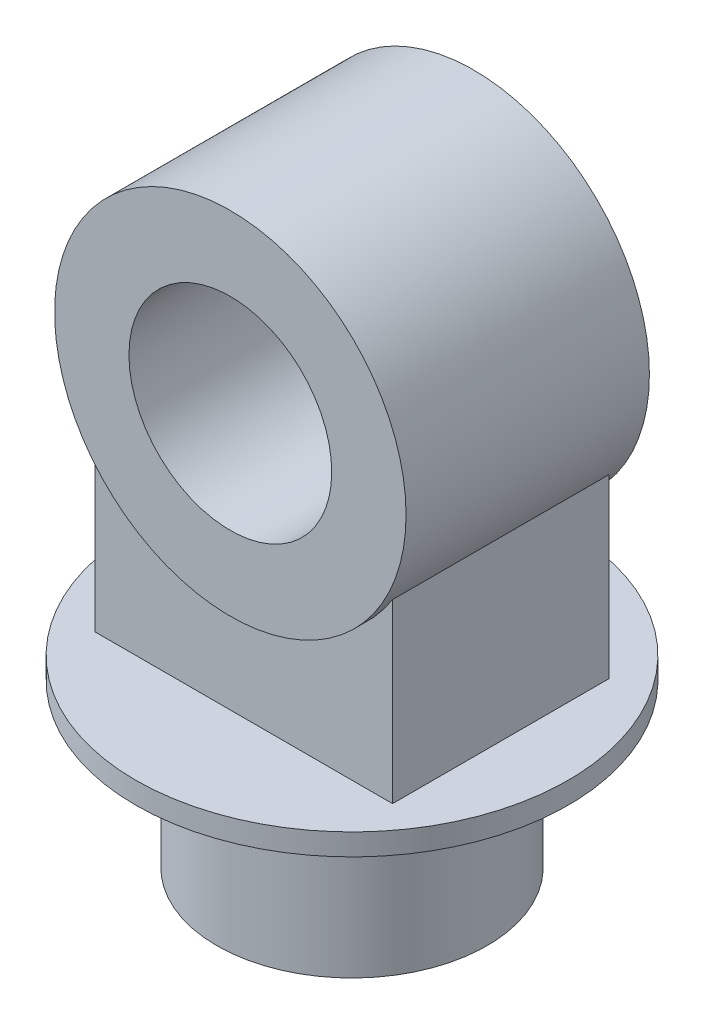
from build123d import *

# Parameters (mm, degrees)
SKETCH1_R                = 100
BOSS_EXTRUDE1_DEPTH      = 120
SKETCH2_R                = 160
BOSS_EXTRUDE2_DEPTH      = 16
SKETCH3_R                = 130
SKETCH3_R_2              = 75
BOSS_EXTRUDE3_DEPTH      = 90
BOSS_EXTRUDE4_REACH      = 402.125
BOSS_EXTRUDE4_END_RADIUS = 130
SKETCH4_W                = 220
SKETCH4_H                = 160


with BuildPart() as part:
    # Sketch1 → Boss-Extrude1 (new body)
    with BuildSketch(Plane(origin=(0, 0, 0), x_dir=(1, 0, 0), z_dir=(0, 1, 0))):
        with Locations(Location((0, 0, 0), (0, 0, 270))):
            Circle(SKETCH1_R)
    extrude(amount=BOSS_EXTRUDE1_DEPTH)

    # Sketch2 → Boss-Extrude2 (add)
    with BuildSketch(Plane(origin=(0, 120, 0), x_dir=(1, 0, 0), z_dir=(0, 1, 0))):
        with Locations(Location((0, 0, 0), (0, 0, 270))):
            Circle(SKETCH2_R)
    extrude(amount=BOSS_EXTRUDE2_DEPTH)



with BuildPart() as body_2:
    # Sketch3 → Boss-Extrude3 (new, symmetric)
    with BuildSketch(Plane.XY):
        with Locations(Location((0, 336, 0), (0, 0, 180))):
            Circle(SKETCH3_R)
        with Locations(Location((0, 336, 0), (0, 0, 180))):
            Circle(SKETCH3_R_2, mode=Mode.SUBTRACT)
    extrude(amount=BOSS_EXTRUDE3_DEPTH, both=True)


with BuildPart() as part_1:
    add(part.part)

    add(body_2.part)  # Boss-Extrude4 merges body 2
    # Boss-Extrude4: up to this cylinder (the profile starts outside it)
    boss_extrude4_end = Plane(origin=(0, 336, 0), z_dir=(0, 0, -1)) * Cylinder(BOSS_EXTRUDE4_END_RADIUS, 1065.25, mode=Mode.PRIVATE)
    # Sketch4 → Boss-Extrude4 (add, up to the surface)
    with BuildSketch(Plane(origin=(0, 136, 0), x_dir=(1, 0, 0), z_dir=(0, 1, 0)), mode=Mode.PRIVATE) as boss_extrude4_sk1:
        Rectangle(SKETCH4_W, SKETCH4_H)
    boss_extrude4_tool1 = extrude(boss_extrude4_sk1.sketch, amount=BOSS_EXTRUDE4_REACH, mode=Mode.PRIVATE) - boss_extrude4_end
    add(boss_extrude4_tool1.solids().sort_by_distance((0, 136, 0))[0])


solid = part_1.part
